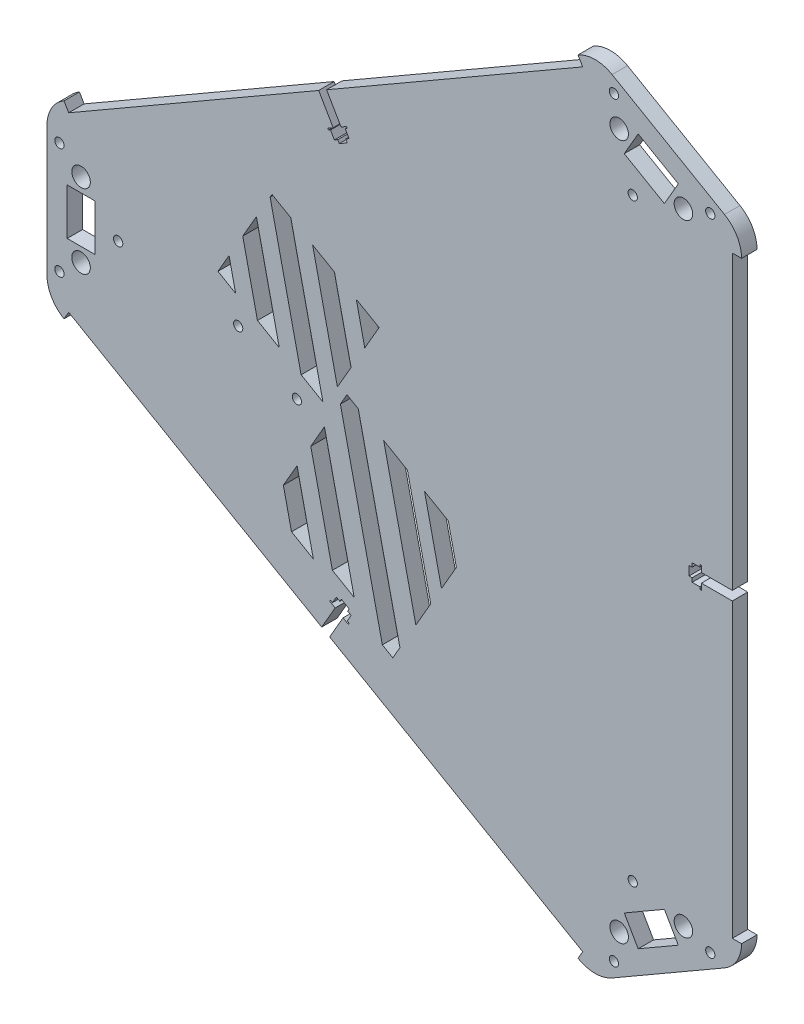
from build123d import *

# Parameters (mm, degrees)
SKETCH1_R           = 3
SKETCH1_R_2         = 1.5
SKETCH1_W           = 9
SKETCH1_H           = 15
BOSS_EXTRUDE1_DEPTH = 5
CUT_EXTRUDE1_DEPTH  = 6
CUT_EXTRUDE2_DEPTH  = 6
CUT_EXTRUDE3_DEPTH  = 10
SKETCH4_R           = 1.5
CUT_EXTRUDE4_DEPTH  = 10


with BuildPart() as part:
    # Sketch1 → Boss-Extrude1 (new body)
    with BuildSketch(Plane.XY):
        with BuildLine():
            Line((-127.0125, 27.949853865), (39.300966521, 123.970978531))
            Line((39.300966521, 123.970978531), (37.800966521, 126.569054742))
            ThreePointArc((37.800966521, 126.569054742), (43.313466521, 128.046124665), (48.825966521, 126.569054742))
            Line((48.825966521, 126.569054742), (85.199033479, 105.569054742))
            ThreePointArc((85.199033479, 105.569054742), (89.234463556, 101.533624665), (90.711533479, 96.021124665))
            Line((90.711533479, 96.021124665), (87.711533479, 96.021124665))
            Line((87.711533479, 96.021124665), (87.711533479, -96.021124665))
            Line((87.711533479, -96.021124665), (90.711533479, -96.021124665))
            ThreePointArc((90.711533479, -96.021124665), (89.234463556, -101.533624665), (85.199033479, -105.569054742))
            Line((85.199033479, -105.569054742), (48.825966521, -126.569054742))
            ThreePointArc((48.825966521, -126.569054742), (43.313465898, -128.046124665), (37.800965443, -126.56905412))
            Line((37.800965443, -126.56905412), (39.300965736, -123.970978078))
            Line((39.300965736, -123.970978078), (-127.012489947, -27.949834641))
            Line((-127.012489947, -27.949834641), (-128.512501078, -30.547929455))
            ThreePointArc((-128.512501078, -30.547929455), (-132.547930388, -26.512499461), (-134.025, -21))
            Line((-134.025, -21), (-134.025, 21))
            ThreePointArc((-134.025, 21), (-132.547930077, 26.5125), (-128.5125, 30.547930077))
            Line((-128.5125, 30.547930077), (-127.0125, 27.949853865))
        make_face()
        with Locations((-123, 12)):
            Circle(SKETCH1_R, mode=Mode.SUBTRACT)
        with Locations((-123, -12)):
            Circle(SKETCH1_R, mode=Mode.SUBTRACT)
        with Locations((71.892304845, 100.521124665)):
            Circle(SKETCH1_R, mode=Mode.SUBTRACT)
        with Locations((51.107695155, 112.521124665)):
            Circle(SKETCH1_R, mode=Mode.SUBTRACT)
        with Locations((51.107695155, -112.521124665)):
            Circle(SKETCH1_R, mode=Mode.SUBTRACT)
        with Locations((71.892304845, -100.521124665)):
            Circle(SKETCH1_R, mode=Mode.SUBTRACT)
        with Locations((-111, 0)):
            Circle(SKETCH1_R_2, mode=Mode.SUBTRACT)
        with Locations((55.5, 96.12881982)):
            Circle(SKETCH1_R_2, mode=Mode.SUBTRACT)
        with Locations((55.5, -96.12881982)):
            Circle(SKETCH1_R_2, mode=Mode.SUBTRACT)
        with Locations((-130, 18)):
            Circle(SKETCH1_R_2, mode=Mode.SUBTRACT)
        with Locations((-130, -18)):
            Circle(SKETCH1_R_2, mode=Mode.SUBTRACT)
        with Locations((80.588457268, 103.583302492)):
            Circle(SKETCH1_R_2, mode=Mode.SUBTRACT)
        with Locations((49.411542732, 121.583302492)):
            Circle(SKETCH1_R_2, mode=Mode.SUBTRACT)
        with Locations((49.411542732, -121.583302492)):
            Circle(SKETCH1_R_2, mode=Mode.SUBTRACT)
        with Locations((80.588457268, -103.583302492)):
            Circle(SKETCH1_R_2, mode=Mode.SUBTRACT)
        Polygon((57.254809472, -114.168238983), (70.245190528, -106.668238983), (65.745190528, -98.874010348), (52.754809472, -106.374010348), align=None, mode=Mode.SUBTRACT)
        with Locations((-123, 0)):
            Rectangle(SKETCH1_W, SKETCH1_H, mode=Mode.SUBTRACT)
        Polygon((65.745190528, 98.874010348), (52.754809472, 106.374010348), (57.254809472, 114.168238983), (70.245190528, 106.668238983), align=None, mode=Mode.SUBTRACT)
    extrude(amount=BOSS_EXTRUDE1_DEPTH)

    # Sketch2 → Cut-Extrude1 (cut, through all)
    with BuildSketch(Plane.XY.offset(5)):
        Polygon((87.711533479, 1.48), (77.711533479, 1.48), (77.711533479, 3.5), (77.211533479, 3.5), (77.211533479, 2.75), (74.711533479, 2.75), (74.711533479, 1.48), (73.711533479, 1.48), (73.711533479, -1.48), (74.711533479, -1.48), (74.711533479, -2.75), (77.211533479, -2.75), (77.211533479, -3.5), (77.711533479, -3.5), (77.711533479, -1.48), (87.711533479, -1.48), align=None)
        Polygon((-43.223568195, -77.825416198), (-38.223568195, -69.16516216), (-36.474196879, -70.17516216), (-36.224196879, -69.742149458), (-36.873715932, -69.367149458), (-35.623715932, -67.202085949), (-36.723568195, -66.567085949), (-36.223568195, -65.701060545), (-38.78700339, -64.221060545), (-39.28700339, -65.087085949), (-40.386855653, -64.452085949), (-41.636855653, -66.617149458), (-42.286374706, -66.242149458), (-42.536374706, -66.67516216), (-40.78700339, -67.68516216), (-45.78700339, -76.345416198), align=None)
        Polygon((-46.436522443, 75.220416198), (-41.436522443, 66.56016216), (-43.185893759, 65.55016216), (-42.935893759, 65.117149458), (-42.286374706, 65.492149458), (-41.036374706, 63.327085949), (-39.936522443, 63.962085949), (-39.436522443, 63.096060545), (-36.873087248, 64.576060545), (-37.373087248, 65.442085949), (-36.273234985, 66.077085949), (-37.523234985, 68.242149458), (-36.873715932, 68.617149458), (-37.123715932, 69.05016216), (-38.873087248, 68.04016216), (-43.873087248, 76.700416198), align=None)
    extrude(amount=-CUT_EXTRUDE1_DEPTH, mode=Mode.SUBTRACT)

    # Sketch3 → Cut-Extrude2 (cut, through all)
    with BuildSketch(Plane.XY.offset(5)):
        Polygon((-57.539549529, -41.661428389), (-54.909843958, -53.412518972), (-47.84919289, -57.488988829), (-53.108604032, -33.986807663), align=None)
        Polygon((-48.677658535, -26.312186937), (-41.678771487, -57.587382375), (-34.618120419, -61.663852232), (-44.246713038, -18.637566211), align=None)
        Polygon((-39.093651522, -9.712204179), (-25.516557684, -70.382745138), (-22.133329048, -72.336053611), (-19.825544935, -68.338855316), (-33.293067707, -8.157943131), (-36.970490138, -6.034781747), align=None)
        Polygon((-25.081734637, -12.898759725), (-14.672483419, -59.413493284), (-9.856238314, -51.071514234), (-17.407113911, -17.329705222), align=None)
        Polygon((-11.868595954, -20.527370889), (-6.380514763, -45.05138602), (-1.564269657, -36.70940697), (-4.193975228, -24.958316386), align=None)
    extrude(amount=-CUT_EXTRUDE2_DEPTH, mode=Mode.SUBTRACT)

    # Sketch5 → Cut-Extrude3 (cut)
    with BuildSketch(Plane.XY.offset(5)):
        Polygon((-40.061292463, -5.388208187), (-48.069042542, 30.395188095), (-41.008391474, 26.318718238), (-35.630346966, 2.286412538), align=None)
        Polygon((-66.256008164, 29.241209516), (-58.864982983, -3.786292638), (-65.92563405, 0.290177219), (-70.686953661, 21.56658879), align=None)
        Polygon((-33.947740407, 22.242248381), (-31.199401469, 9.961033264), (-26.568563639, 17.981877577), align=None)
        Polygon((-55.12969361, 34.471657952), (-44.743680847, -11.939232352), (-51.804331915, -7.862762495), (-61.825062667, 36.915830242), (-61.209577533, 37.981881487), align=None)
        Polygon((-75.117899158, 13.891968064), (-72.986285118, 4.366647077), (-78.709580954, 7.670994329), align=None)
    extrude(amount=-CUT_EXTRUDE3_DEPTH, mode=Mode.SUBTRACT)

    # Sketch4 → Cut-Extrude4 (cut)
    with BuildSketch(Plane.XY.offset(5)):
        with Locations((-72.175794174, -4.380771204)):
            Circle(SKETCH4_R)
        with Locations((-53.162424939, -15.35814505)):
            Circle(SKETCH4_R)
    extrude(amount=-CUT_EXTRUDE4_DEPTH, mode=Mode.SUBTRACT)


solid = part.part
